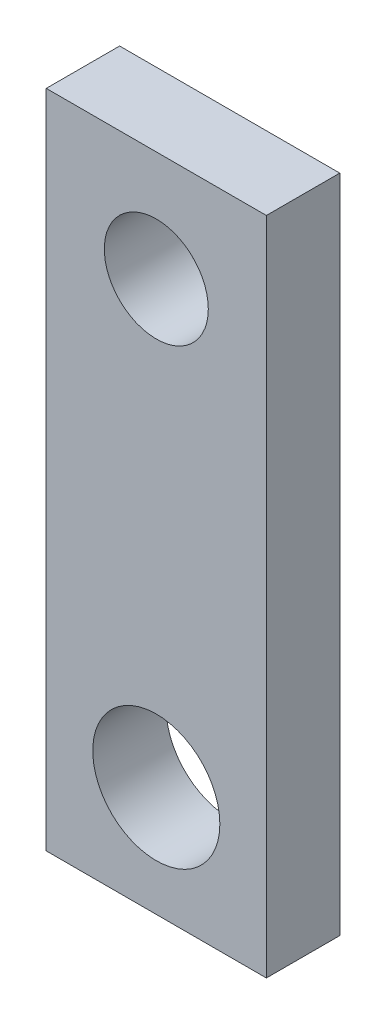
from build123d import *

# Parameters (mm, degrees)
SKETCH1_W                 = 19.05
SKETCH1_H                 = 57.15
BOSS_EXTRUDE1_DEPTH       = 6.35
M10_CLEARANCE_HOLE1_D     = 11
M10_CLEARANCE_HOLE1_DEPTH = 25.4
M10_CLEARANCE_HOLE1_TIP   = 3.304733405
M8_CLEARANCE_HOLE2_D      = 9
M8_CLEARANCE_HOLE2_DEPTH  = 25.4
M8_CLEARANCE_HOLE2_TIP    = 2.703872786


with BuildPart() as part:
    # Sketch1 → Boss-Extrude1 (new body)
    with BuildSketch(Plane.XY):
        with Locations((0, 61.356)):
            Rectangle(SKETCH1_W, SKETCH1_H)
    extrude(amount=BOSS_EXTRUDE1_DEPTH)

    # M10 Clearance Hole1
    with Locations(Plane.XY.offset(6.35)):
        with Locations((0, 42.306)):
            Hole(M10_CLEARANCE_HOLE1_D / 2, depth=M10_CLEARANCE_HOLE1_DEPTH)
            with Locations((0, 0, -(M10_CLEARANCE_HOLE1_DEPTH + M10_CLEARANCE_HOLE1_TIP / 2))):  # 118° drill point
                Cone(0, M10_CLEARANCE_HOLE1_D / 2, M10_CLEARANCE_HOLE1_TIP, mode=Mode.SUBTRACT)

    # M8 Clearance Hole2
    with Locations(Plane.XY.offset(6.35)):
        with Locations((0, 80.406)):
            Hole(M8_CLEARANCE_HOLE2_D / 2, depth=M8_CLEARANCE_HOLE2_DEPTH)
            with Locations((0, 0, -(M8_CLEARANCE_HOLE2_DEPTH + M8_CLEARANCE_HOLE2_TIP / 2))):  # 118° drill point
                Cone(0, M8_CLEARANCE_HOLE2_D / 2, M8_CLEARANCE_HOLE2_TIP, mode=Mode.SUBTRACT)


solid = part.part
